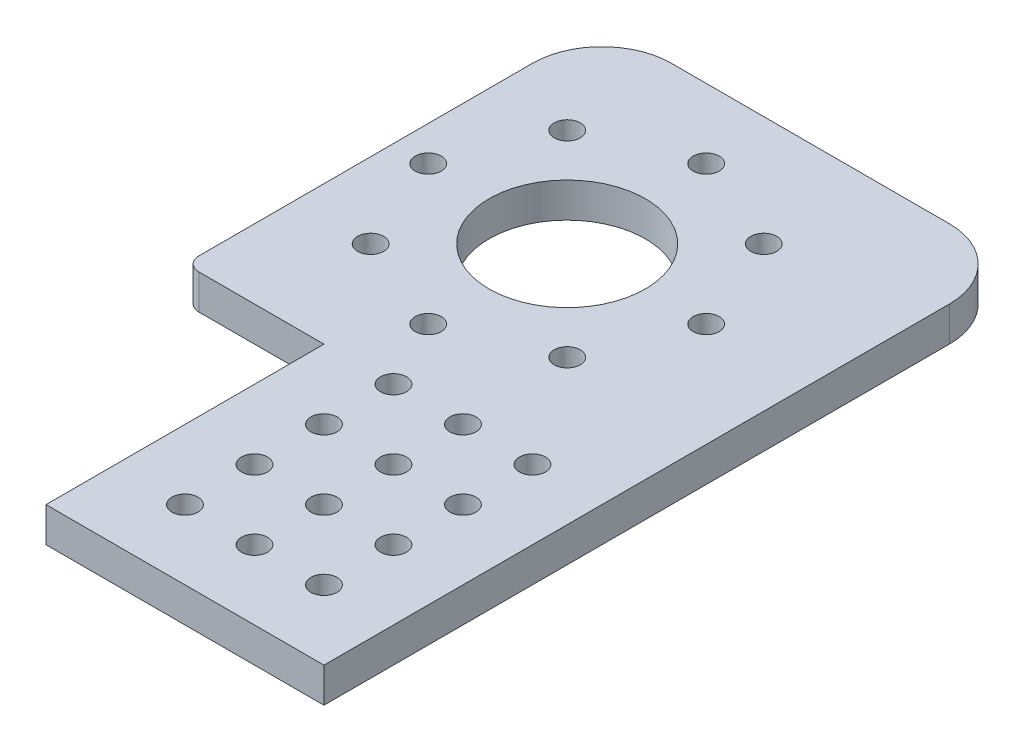
from build123d import *

# Parameters (mm, degrees)
SKETCH1_R           = 2.38125
SKETCH1_R_2         = 14.2875
BOSS_EXTRUDE1_DEPTH = 6.35
FILLET1_R           = 12.7
SKETCH2_R           = 2.38125
CUT_EXTRUDE1_DEPTH  = 7.35
FILLET2_R           = 2.54


with BuildPart() as part:
    # Sketch1 → Boss-Extrude1 (new body)
    with BuildSketch(Plane(origin=(0, 0, 0), x_dir=(1, 0, 0), z_dir=(0, 1, 0))):
        Polygon((0, 0), (50.8, 0), (50.8, 127), (-25.4, 127), (-25.4, 50.8), (0, 50.8), align=None)
        with Locations((12.7, 12.7)):
            Circle(SKETCH1_R, mode=Mode.SUBTRACT)
        with Locations((25.4, 12.7)):
            Circle(SKETCH1_R, mode=Mode.SUBTRACT)
        with Locations((38.1, 12.7)):
            Circle(SKETCH1_R, mode=Mode.SUBTRACT)
        with Locations((25.4, 25.4)):
            Circle(SKETCH1_R, mode=Mode.SUBTRACT)
        with Locations((38.1, 25.4)):
            Circle(SKETCH1_R, mode=Mode.SUBTRACT)
        with Locations((25.4, 38.1)):
            Circle(SKETCH1_R, mode=Mode.SUBTRACT)
        with Locations((38.1, 38.1)):
            Circle(SKETCH1_R, mode=Mode.SUBTRACT)
        with Locations((12.7, 25.4)):
            Circle(SKETCH1_R, mode=Mode.SUBTRACT)
        with Locations((12.7, 38.1)):
            Circle(SKETCH1_R, mode=Mode.SUBTRACT)
        with Locations((6.35, 88.9)):
            Circle(SKETCH1_R_2, mode=Mode.SUBTRACT)
        with Locations((12.7, 50.8)):
            Circle(SKETCH1_R, mode=Mode.SUBTRACT)
        with Locations((25.4, 50.8)):
            Circle(SKETCH1_R, mode=Mode.SUBTRACT)
        with Locations((38.1, 50.8)):
            Circle(SKETCH1_R, mode=Mode.SUBTRACT)
    extrude(amount=BOSS_EXTRUDE1_DEPTH)

    # Fillet1
    fillet1_edges = [part.edges().sort_by_distance(p)[0] for p in [
        (-25.4, 3.175, -127),
        (50.8, 3.175, -127),
    ]]
    fillet(fillet1_edges, radius=FILLET1_R)

    # Sketch2 → Cut-Extrude1 (cut, through all)
    with BuildSketch(Plane(origin=(0, 6.35, 0), x_dir=(1, 0, 0), z_dir=(0, 1, 0))):
        with Locations((-19.05, 88.9)):
            Circle(SKETCH2_R)
        with Locations((-11.610512242, 106.860512242)):
            Circle(SKETCH2_R)
        with Locations((6.35, 114.3)):
            Circle(SKETCH2_R)
        with Locations((24.310512242, 106.860512242)):
            Circle(SKETCH2_R)
        with Locations((31.75, 88.9)):
            Circle(SKETCH2_R)
        with Locations((24.310512242, 70.939487758)):
            Circle(SKETCH2_R)
        with Locations((6.35, 63.5)):
            Circle(SKETCH2_R)
        with Locations((-11.610512242, 70.939487758)):
            Circle(SKETCH2_R)
    extrude(amount=-CUT_EXTRUDE1_DEPTH, mode=Mode.SUBTRACT)

    # Fillet2
    fillet2_edges = [part.edges().sort_by_distance(p)[0] for p in [
        (-25.4, 3.175, -50.8),
    ]]
    fillet(fillet2_edges, radius=FILLET2_R)


solid = part.part
